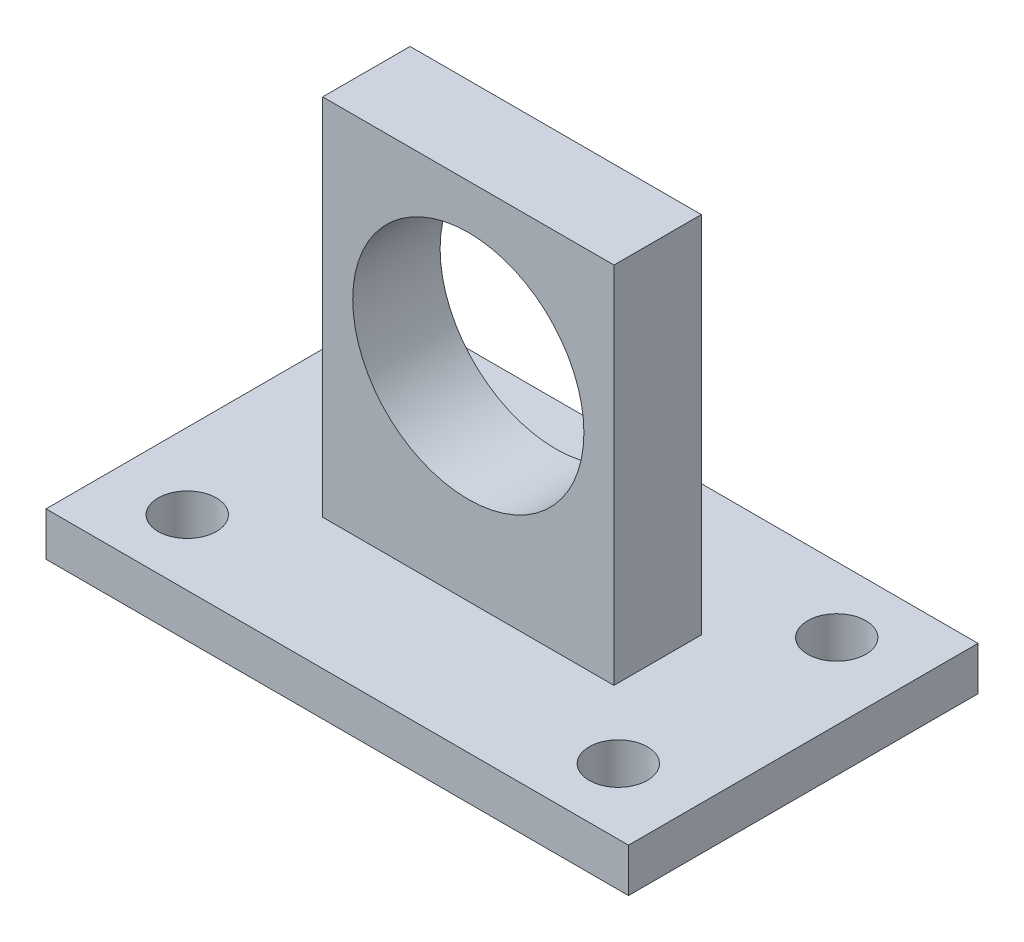
from build123d import *

# Parameters (mm, degrees)
SKETCH_1_W          = 40
SKETCH_1_H          = 24
SKETCH_1_R          = 2
EXTRUDE_1_DEPTH     = 3
SKETCH_2_W          = 20
SKETCH_2_H          = 6
EXTRUDE_2_DEPTH     = 25
SKETCH_3_R          = 7.9375
CUT_EXTRUDE_1_DEPTH = 10


with BuildPart() as part:
    # 草图1 → 凸台-拉伸1 (new body)
    with BuildSketch(Plane(origin=(0, 0, 0), x_dir=(1, 0, 0), z_dir=(0, 1, 0))):
        Rectangle(SKETCH_1_W, SKETCH_1_H)
        with Locations((-14.8, -7.5)):
            Circle(SKETCH_1_R, mode=Mode.SUBTRACT)
        with Locations((14.8, -7.5)):
            Circle(SKETCH_1_R, mode=Mode.SUBTRACT)
        with Locations((-14.8, 7.5)):
            Circle(SKETCH_1_R, mode=Mode.SUBTRACT)
        with Locations((14.8, 7.5)):
            Circle(SKETCH_1_R, mode=Mode.SUBTRACT)
    extrude(amount=EXTRUDE_1_DEPTH)

    # 草图2 → 凸台-拉伸2 (add)
    with BuildSketch(Plane(origin=(0, 3, 0), x_dir=(1, 0, 0), z_dir=(0, 1, 0))):
        Rectangle(SKETCH_2_W, SKETCH_2_H)
    extrude(amount=EXTRUDE_2_DEPTH)

    # 草图3 → 切除-拉伸1 (cut)
    with BuildSketch(Plane.XY.offset(3)):
        with Locations((0, 17)):
            Circle(SKETCH_3_R)
    extrude(amount=-CUT_EXTRUDE_1_DEPTH, mode=Mode.SUBTRACT)


solid = part.part
